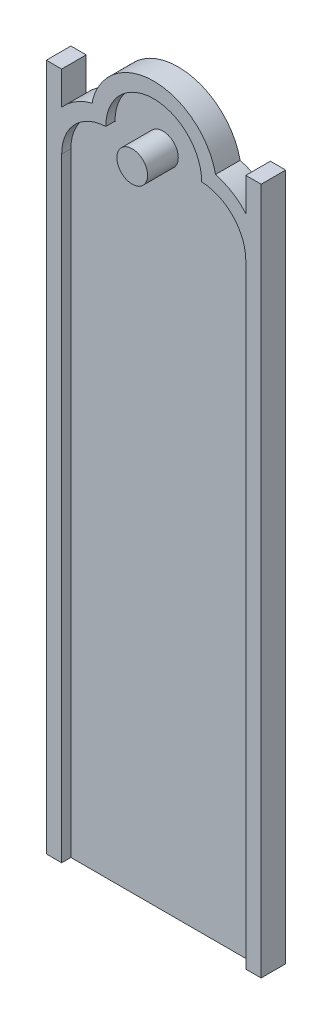
from build123d import *

# Parameters (mm, degrees)
SKETCH2_R           = 50
BOSS_EXTRUDE3_DEPTH = 50
BOSS_EXTRUDE4_DEPTH = 80
SKETCH2_9_R         = 50
BOSS_EXTRUDE5_DEPTH = 150


with BuildPart() as part:
    # Sketch2 → Boss-Extrude3 (new body)
    with BuildSketch(Plane.XY):
        with BuildLine():
            Line((-283.78190134, 487.937190165), (-283.78190134, -1512.062809835))
            Line((-283.78190134, -1512.062809835), (316.21809866, -1512.062809835))
            Line((316.21809866, -1512.062809835), (316.21809866, 487.937190165))
            ThreePointArc((316.21809866, 487.937190165), (274.438439922, 591.804209653), (172.37332883, 637.810847428))
            ThreePointArc((172.37332883, 637.810847428), (169.296362007, 637.905601155), (166.21809866, 637.937190165))
            Line((166.21809866, 637.937190165), (172.373379941, 637.937190165))
            ThreePointArc((172.373379941, 637.937190165), (16.21809866, 794.092471446), (-139.937182621, 637.937190165))
            Line((-139.937182621, 637.937190165), (-139.660119377, 637.937190165))
            Line((-139.660119377, 637.937190165), (-133.78190134, 637.937190165))
            ThreePointArc((-133.78190134, 637.937190165), (-136.860164687, 637.905601155), (-139.93713151, 637.810847428))
            ThreePointArc((-139.93713151, 637.810847428), (-242.002242601, 591.804209653), (-283.78190134, 487.937190165))
        make_face()
        with Locations((16.21809866, 637.937190165)):
            Circle(SKETCH2_R, mode=Mode.SUBTRACT)
    extrude(amount=BOSS_EXTRUDE3_DEPTH)

    # Sketch2_8 → Boss-Extrude4 (add)
    with BuildSketch(Plane.XY):
        with BuildLine():
            Line((-333.78190134, 487.937190165), (-333.78190134, -1512.062809835))
            Line((-333.78190134, -1512.062809835), (-283.78190134, -1512.062809835))
            Line((-283.78190134, -1512.062809835), (-283.78190134, 487.937190165))
            ThreePointArc((-283.78190134, 487.937190165), (-242.002242601, 591.804209653), (-139.93713151, 637.810847428))
            ThreePointArc((-139.93713151, 637.810847428), (-139.937169843, 637.874018792), (-139.937182621, 637.937190165))
            ThreePointArc((-139.937182621, 637.937190165), (16.21809866, 794.092471446), (172.373379941, 637.937190165))
            ThreePointArc((172.373379941, 637.937190165), (172.373367163, 637.874018792), (172.37332883, 637.810847428))
            ThreePointArc((172.37332883, 637.810847428), (274.438439922, 591.804209653), (316.21809866, 487.937190165))
            Line((316.21809866, 487.937190165), (316.21809866, -1512.062809835))
            Line((316.21809866, -1512.062809835), (366.21809866, -1512.062809835))
            Line((366.21809866, -1512.062809835), (366.21809866, 487.937190165))
            Line((366.21809866, 487.937190165), (366.21809866, 727.937190165))
            Line((366.21809866, 727.937190165), (316.21809866, 727.937190165))
            Line((316.21809866, 727.937190165), (316.21809866, 620.224755718))
            ThreePointArc((316.21809866, 620.224755718), (271.509827539, 657.977337865), (217.788355507, 681.174113678))
            ThreePointArc((217.788355507, 681.174113678), (19.689586458, 844.063240853), (-183.78190134, 687.937190165))
            Line((-183.78190134, 687.937190165), (-183.78190134, 681.586357475))
            ThreePointArc((-183.78190134, 681.586357475), (-184.567448055, 681.381828873), (-185.352158186, 681.174113678))
            ThreePointArc((-185.352158186, 681.174113678), (-239.073630218, 657.977337865), (-283.78190134, 620.224755718))
            Line((-283.78190134, 620.224755718), (-283.78190134, 727.937190165))
            Line((-283.78190134, 727.937190165), (-333.78190134, 727.937190165))
            Line((-333.78190134, 727.937190165), (-333.78190134, 487.937190165))
        make_face()
    extrude(amount=BOSS_EXTRUDE4_DEPTH)

    # Sketch2_9 → Boss-Extrude5 (add)
    with BuildSketch(Plane.XY):
        with Locations((16.21809866, 637.937190165)):
            Circle(SKETCH2_9_R)
    extrude(amount=BOSS_EXTRUDE5_DEPTH)


solid = part.part
